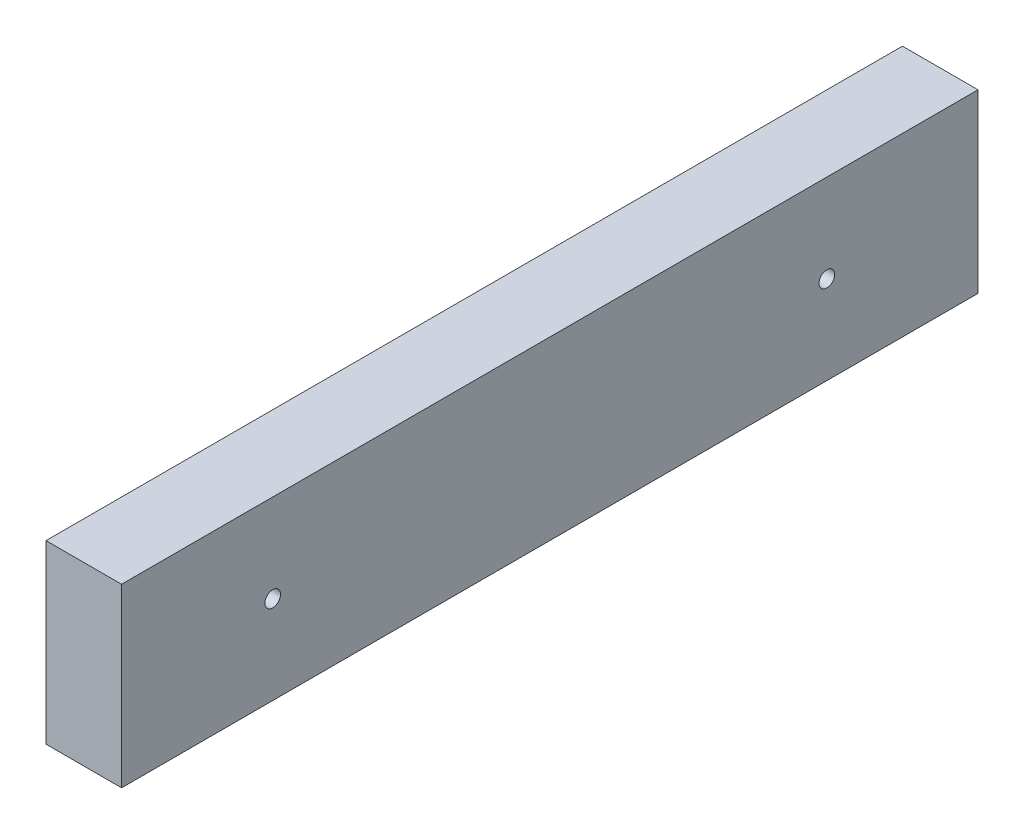
from build123d import *

# Parameters (mm, degrees)
SKETCH1_W                      = 38.1
SKETCH1_H                      = 88.9
BOSS_EXTRUDE1_DEPTH            = 431.8
F_5_16_0_3125_DIAMETER_HOLE1_D = 7.9375


with BuildPart() as part:
    # Sketch1 → Boss-Extrude1 (new body)
    with BuildSketch(Plane.XY):
        Rectangle(SKETCH1_W, SKETCH1_H)
    extrude(amount=BOSS_EXTRUDE1_DEPTH)

    # 5/16 (0.3125) Diameter Hole1 (through all)
    with Locations(Plane(origin=(19.05, 0, 0), x_dir=(0, 0, -1), z_dir=(1, 0, 0))):
        with Locations((-355.6, 0), (-76.2, 0)):
            Hole(F_5_16_0_3125_DIAMETER_HOLE1_D / 2)


solid = part.part
